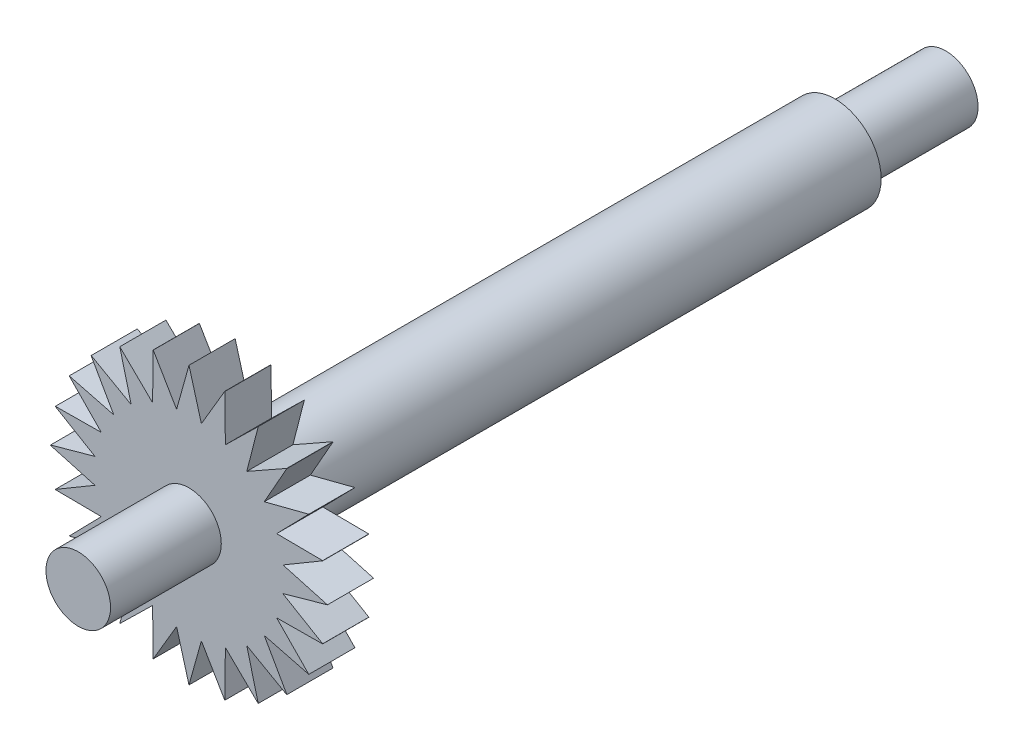
from build123d import *

# Parameters (mm, degrees)
ESQUISSE1_R             = 5
BOSS_EXTRU_2_DEPTH      = 70
ESQUISSE2_R             = 3.5
BOSS_EXTRU_3_DEPTH      = 12
ESQUISSE4_R             = 15
BOSS_EXTRU_5_DEPTH      = 5
ESQUISSE5_R             = 3.5
BOSS_EXTRU_6_DEPTH      = 12
ENL_V_MAT_EXTRU_1_DEPTH = 12


with BuildPart() as part:
    # Esquisse1 → Boss.-Extru.2 (new body)
    with BuildSketch(Plane.XY):
        Circle(ESQUISSE1_R)
    extrude(amount=BOSS_EXTRU_2_DEPTH)

    # Esquisse2 → Boss.-Extru.3 (add)
    with BuildSketch(Plane(origin=(0, 0, 0), x_dir=(-1, 0, 0), z_dir=(0, 0, -1))):
        Circle(ESQUISSE2_R)
    extrude(amount=BOSS_EXTRU_3_DEPTH)

    # Esquisse4 → Boss.-Extru.5 (add)
    with BuildSketch(Plane.XY.offset(70)):
        Circle(ESQUISSE4_R)
    extrude(amount=-BOSS_EXTRU_5_DEPTH)

    # Esquisse5 → Boss.-Extru.6 (add)
    with BuildSketch(Plane.XY.offset(70)):
        Circle(ESQUISSE5_R)
    extrude(amount=BOSS_EXTRU_6_DEPTH)

    # Esquisse6 → Enlèv. mat.-Extru.1 (cut)
    with BuildSketch(Plane.XY.offset(70)):
        with BuildLine():
            Line((-6.262893089, 8.172072336), (-7.499435292, 12.990707074))
            ThreePointArc((-7.499435292, 12.990707074), (-9.123657799, 11.90625333), (-10.593218546, 10.619968024))
            Line((-10.593218546, 10.619968024), (-6.262893089, 8.172072336))
        make_face()
        with BuildLine():
            Line((-8.152402023, 6.270263162), (-10.606442664, 10.606760769))
            ThreePointArc((-10.606442664, 10.606760769), (-11.894621233, 9.138817524), (-12.981158937, 7.515950549))
            Line((-12.981158937, 7.515950549), (-8.152402023, 6.270263162))
        make_face()
        with BuildLine():
            Line((-9.499942261, 3.951679007), (-12.981158937, 7.515950549))
            ThreePointArc((-12.981158937, 7.515950549), (-13.849269023, 5.761748652), (-14.481582106, 3.909447494))
            Line((-14.481582106, 3.909447494), (-9.499942261, 3.951679007))
        make_face()
        with BuildLine():
            Line((-10.188028074, 1.356459322), (-14.486441985, 3.891400598))
            ThreePointArc((-14.486441985, 3.891400598), (-14.869805294, 1.972027008), (-14.999987869, 0.0190767))
            Line((-14.999987869, 0.0190767), (-10.188028074, 1.356459322))
        make_face()
        with BuildLine():
            ThreePointArc((-14.999987869, -0.0190767), (-14.869805294, -1.972027008), (-14.486441985, -3.891400598))
            Line((-14.486441985, -3.891400598), (-10.188028074, -1.356459322))
            Line((-10.188028074, -1.356459322), (-14.999987869, -0.0190767))
        make_face()
        with BuildLine():
            Line((-9.499942261, -3.951679007), (-14.481582106, -3.909447494))
            ThreePointArc((-14.481582106, -3.909447494), (-13.849269023, -5.761748652), (-12.981158937, -7.515950549))
            Line((-12.981158937, -7.515950549), (-9.499942261, -3.951679007))
        make_face()
        with BuildLine():
            Line((-8.152402023, -6.270263162), (-12.981158937, -7.515950549))
            ThreePointArc((-12.981158937, -7.515950549), (-11.894621233, -9.138817524), (-10.606442664, -10.606760769))
            Line((-10.606442664, -10.606760769), (-8.152402023, -6.270263162))
        make_face()
        with BuildLine():
            Line((-6.262893089, -8.172072336), (-10.593218546, -10.619968024))
            ThreePointArc((-10.593218546, -10.619968024), (-9.123657799, -11.90625333), (-7.499435292, -12.990707074))
            Line((-7.499435292, -12.990707074), (-6.262893089, -8.172072336))
        make_face()
        with BuildLine():
            Line((-3.939593974, -9.504960245), (-7.499435292, -12.990707074))
            ThreePointArc((-7.499435292, -12.990707074), (-5.744130769, -13.8565855), (-3.891026946, -14.486542352))
            Line((-3.891026946, -14.486542352), (-3.939593974, -9.504960245))
        make_face()
        with BuildLine():
            Line((-1.343501295, -10.189744953), (-3.872973884, -14.491379275))
            ThreePointArc((-3.872973884, -14.491379275), (-1.953114292, -14.872301253), (0, -15))
            Line((0, -15), (-1.343501295, -10.189744953))
        make_face()
        with BuildLine():
            ThreePointArc((0, -15), (1.953114292, -14.872301253), (3.872973884, -14.491379275))
            Line((3.872973884, -14.491379275), (1.343501295, -10.189744953))
            Line((1.343501295, -10.189744953), (0, -15))
        make_face()
        with BuildLine():
            ThreePointArc((3.891026946, -14.486542352), (5.744130769, -13.8565855), (7.499435292, -12.990707074))
            Line((7.499435292, -12.990707074), (3.939593974, -9.504960245))
            Line((3.939593974, -9.504960245), (3.891026946, -14.486542352))
        make_face()
        with BuildLine():
            ThreePointArc((7.499435292, -12.990707074), (9.123657799, -11.90625333), (10.593218546, -10.619968024))
            Line((10.593218546, -10.619968024), (6.262893089, -8.172072336))
            Line((6.262893089, -8.172072336), (7.499435292, -12.990707074))
        make_face()
        with BuildLine():
            ThreePointArc((10.606442664, -10.606760769), (11.894621233, -9.138817524), (12.981158937, -7.515950549))
            Line((12.981158937, -7.515950549), (8.152402023, -6.270263162))
            Line((8.152402023, -6.270263162), (10.606442664, -10.606760769))
        make_face()
        with BuildLine():
            ThreePointArc((12.981158937, -7.515950549), (13.849269023, -5.761748652), (14.481582106, -3.909447494))
            Line((14.481582106, -3.909447494), (9.499942261, -3.951679007))
            Line((9.499942261, -3.951679007), (12.981158937, -7.515950549))
        make_face()
        with BuildLine():
            ThreePointArc((15, 0), (14.999996967, 0.009538352), (14.999987869, 0.0190767))
            Line((14.999987869, 0.0190767), (10.159352957, -1.339548494))
            Line((10.159352957, -1.339548494), (14.486441985, -3.891400598))
            ThreePointArc((14.486441985, -3.891400598), (14.87105628, -1.962571047), (15, 0))
        make_face()
        with BuildLine():
            ThreePointArc((14.999987869, 0.0190767), (14.869805294, 1.972027008), (14.486441985, 3.891400598))
            Line((14.486441985, 3.891400598), (10.188028074, 1.356459322))
            Line((10.188028074, 1.356459322), (14.999987869, 0.0190767))
        make_face()
        with BuildLine():
            ThreePointArc((14.481582106, 3.909447494), (13.849269023, 5.761748652), (12.981158937, 7.515950549))
            Line((12.981158937, 7.515950549), (9.499942261, 3.951679007))
            Line((9.499942261, 3.951679007), (14.481582106, 3.909447494))
        make_face()
        with BuildLine():
            ThreePointArc((12.981158937, 7.515950549), (11.894621233, 9.138817524), (10.606442664, 10.606760769))
            Line((10.606442664, 10.606760769), (8.152402023, 6.270263162))
            Line((8.152402023, 6.270263162), (12.981158937, 7.515950549))
        make_face()
        with BuildLine():
            ThreePointArc((10.593218546, 10.619968024), (9.123657799, 11.90625333), (7.499435292, 12.990707074))
            Line((7.499435292, 12.990707074), (6.262893089, 8.172072336))
            Line((6.262893089, 8.172072336), (10.593218546, 10.619968024))
        make_face()
        with BuildLine():
            ThreePointArc((7.499435292, 12.990707074), (5.744130769, 13.8565855), (3.891026946, 14.486542352))
            Line((3.891026946, 14.486542352), (3.939593974, 9.504960245))
            Line((3.939593974, 9.504960245), (7.499435292, 12.990707074))
        make_face()
        with BuildLine():
            ThreePointArc((3.872973884, 14.491379275), (1.953114292, 14.872301253), (0, 15))
            Line((0, 15), (1.343501295, 10.189744953))
            Line((1.343501295, 10.189744953), (3.872973884, 14.491379275))
        make_face()
        with BuildLine():
            Line((-1.343501295, 10.189744953), (0, 15))
            ThreePointArc((0, 15), (-1.953114292, 14.872301253), (-3.872973884, 14.491379275))
            Line((-3.872973884, 14.491379275), (-1.343501295, 10.189744953))
        make_face()
        with BuildLine():
            Line((-3.939593974, 9.504960245), (-3.891026946, 14.486542352))
            ThreePointArc((-3.891026946, 14.486542352), (-5.744130769, 13.8565855), (-7.499435292, 12.990707074))
            Line((-7.499435292, 12.990707074), (-3.939593974, 9.504960245))
        make_face()
    extrude(amount=-ENL_V_MAT_EXTRU_1_DEPTH, mode=Mode.SUBTRACT)


solid = part.part
